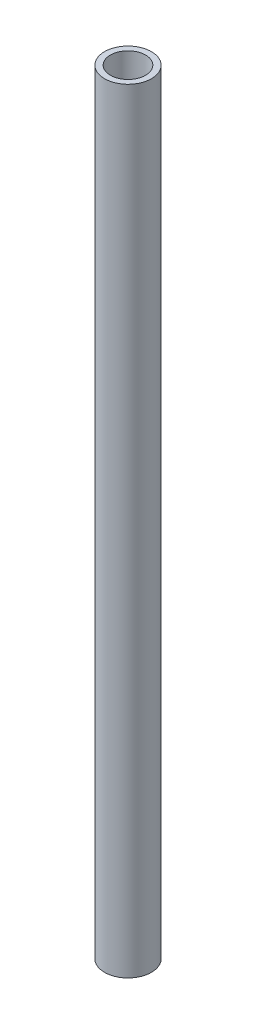
from build123d import *

# Parameters (mm, degrees)
SKETCH1_R           = 12.7
SKETCH1_R_2         = 9.525
BOSS_EXTRUDE2_DEPTH = 419.1


with BuildPart() as part:
    # Sketch1 → Boss-Extrude2 (new body)
    with BuildSketch(Plane(origin=(0, 0, 0), x_dir=(1, 0, 0), z_dir=(0, 1, 0))):
        with Locations((-391.181668083, 212.743279788)):
            Circle(SKETCH1_R)
        with Locations((-391.181668083, 212.743279788)):
            Circle(SKETCH1_R_2, mode=Mode.SUBTRACT)
    extrude(amount=BOSS_EXTRUDE2_DEPTH)


solid = part.part
